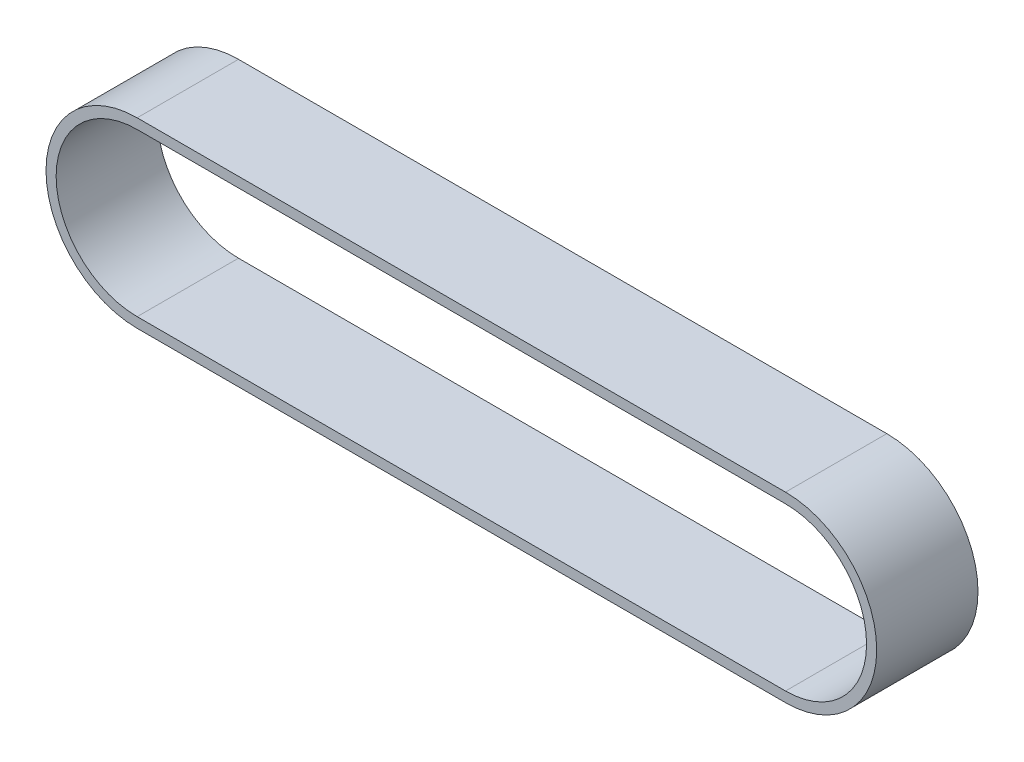
from build123d import *

# Parameters (mm, degrees)
BOSS_EXTRUDE1_DEPTH = 50


with BuildPart() as part:
    # Sketch1 → Boss-Extrude1 (new body)
    with BuildSketch(Plane.XY):
        with BuildLine():
            Line((0, 45), (320, 45))
            ThreePointArc((320, 45), (365, 0), (320, -45))
            Line((320, -45), (0, -45))
            ThreePointArc((0, -45), (-45, 0), (0, 45))
        make_face()
        with BuildLine():
            Line((0, 40), (320, 40))
            ThreePointArc((320, 40), (360, 0), (320, -40))
            Line((320, -40), (0, -40))
            ThreePointArc((0, -40), (-40, 0), (0, 40))
        make_face(mode=Mode.SUBTRACT)
    extrude(amount=BOSS_EXTRUDE1_DEPTH)


solid = part.part
